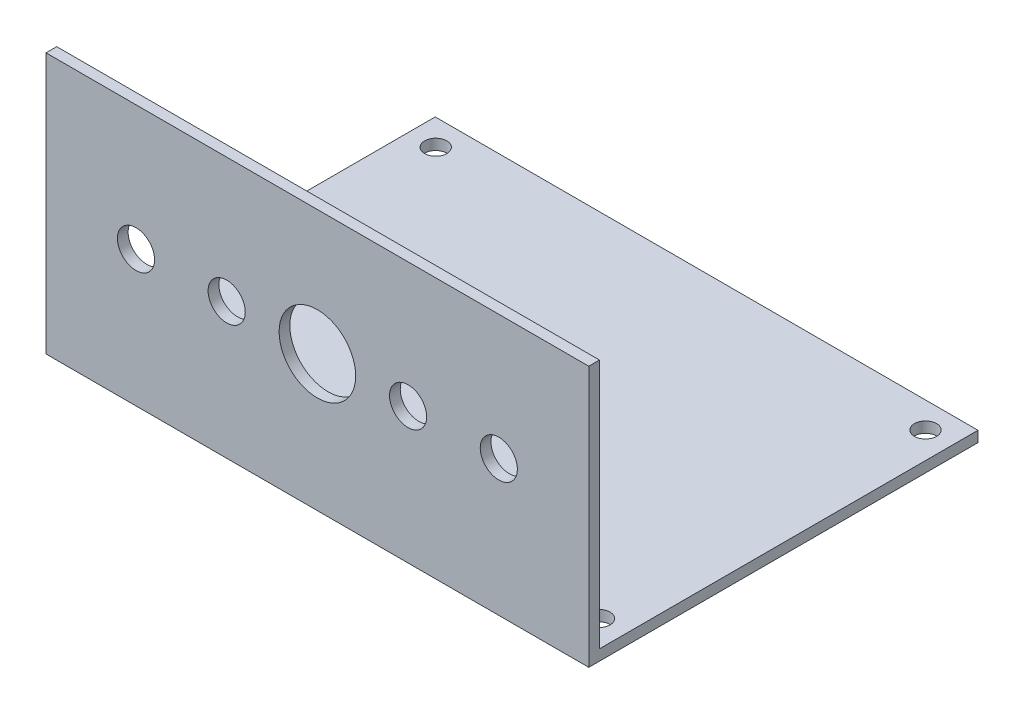
from build123d import *

# Parameters (mm, degrees)
SKETCH_1_W          = 76
SKETCH_1_H          = 53
SKETCH_1_R          = 1.55
EXTRUDE_1_DEPTH     = 1.5
SKETCH_2_W          = 76
SKETCH_2_H          = 1.5
EXTRUDE_2_DEPTH     = 1.5
SKETCH_3_W          = 76
SKETCH_3_H          = 1.5
EXTRUDE_3_DEPTH     = 35.02
SKETCH_4_R          = 5.36
SKETCH_4_R_2        = 2.600000007
CUT_EXTRUDE_1_DEPTH = 60


with BuildPart() as part:
    # 草图1 → 凸台-拉伸1 (new body)
    with BuildSketch(Plane(origin=(0, 0, 0), x_dir=(1, 0, 0), z_dir=(0, 1, 0))):
        Rectangle(SKETCH_1_W, SKETCH_1_H)
        with Locations((-34.29, 22.86)):
            Circle(SKETCH_1_R, mode=Mode.SUBTRACT)
        with Locations((-34.29, -22.86)):
            Circle(SKETCH_1_R, mode=Mode.SUBTRACT)
        with Locations((34.29, -22.86)):
            Circle(SKETCH_1_R, mode=Mode.SUBTRACT)
        with Locations((34.29, 22.86)):
            Circle(SKETCH_1_R, mode=Mode.SUBTRACT)
    extrude(amount=EXTRUDE_1_DEPTH)

    # 草图2 → 凸台-拉伸2 (add)
    with BuildSketch(Plane.XY.offset(26.5)):
        with Locations((0, 0.75)):
            Rectangle(SKETCH_2_W, SKETCH_2_H)
    extrude(amount=EXTRUDE_2_DEPTH)

    # 草图3 → 凸台-拉伸3 (add)
    with BuildSketch(Plane(origin=(0, 1.5, 0), x_dir=(1, 0, 0), z_dir=(0, 1, 0))):
        with Locations((0, -27.25)):
            Rectangle(SKETCH_3_W, SKETCH_3_H)
    extrude(amount=EXTRUDE_3_DEPTH)

    # 草图4 → 切除-拉伸1 (cut)
    with BuildSketch(Plane(origin=(0, 0, 26.5), x_dir=(-1, 0, 0), z_dir=(0, 0, -1))):
        with Locations((0, 19.02)):
            Circle(SKETCH_4_R)
        with Locations((-12.7, 19.02)):
            Circle(SKETCH_4_R_2)
        with Locations((-25.4, 19.02)):
            Circle(SKETCH_4_R_2)
        with Locations((12.7, 19.02)):
            Circle(SKETCH_4_R_2)
        with Locations((25.4, 19.02)):
            Circle(SKETCH_4_R_2)
    extrude(amount=-CUT_EXTRUDE_1_DEPTH, mode=Mode.SUBTRACT)


solid = part.part
